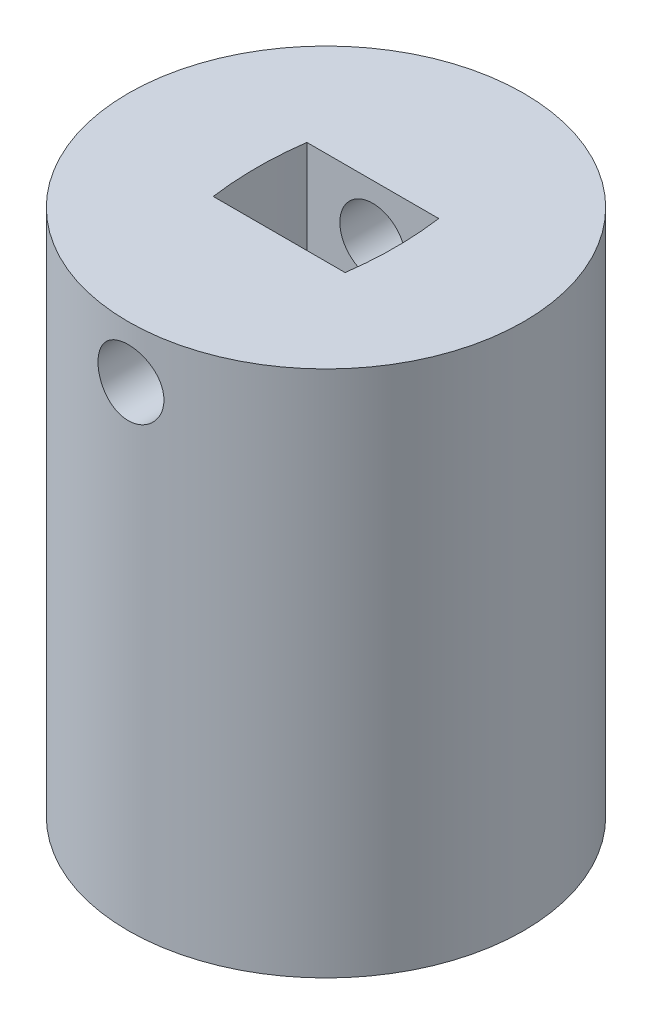
from build123d import *

# Parameters (mm, degrees)
SKETCH1_R               = 15
BOSS_EXTRUDE1_DEPTH     = 40
CUT_EXTRUDE1_DEPTH      = 15
SKETCH3_R               = 2
CUT_EXTRUDE2_DEPTH      = 15
CUT_EXTRUDE3_DEPTH      = 9
SKETCH5_R               = 2.5
CUT_EXTRUDE4_DEPTH      = 19.550000101
CUT_EXTRUDE4_DEPTH_BACK = 12.4500001


with BuildPart() as part:
    # Sketch1 → Boss-Extrude1 (new body)
    with BuildSketch(Plane(origin=(0, 0, 0), x_dir=(1, 0, 0), z_dir=(0, 1, 0))):
        Circle(SKETCH1_R)
    extrude(amount=BOSS_EXTRUDE1_DEPTH)

    # Sketch2 → Cut-Extrude1 (cut)
    with BuildSketch(Plane.XZ):
        with BuildLine():
            Line((-4.000002932, 5), (3.999997068, 5))
            add(Edge.make_bspline(
                [(3.999997068, 5), (8.199974497, 0.009249301), (3.999997068, -5)],
                knots=[0, 0, 0, 1, 1, 1], degree=2))
            Line((3.999997068, -5), (-4.000002932, -5))
            add(Edge.make_bspline(
                [(-4.000002932, 5), (-8.199982148, -0.00561634), (-4.000002932, -5)],
                knots=[0, 0, 0, 1, 1, 1], degree=2))
        make_face()
    extrude(amount=-CUT_EXTRUDE1_DEPTH, mode=Mode.SUBTRACT)

    # Sketch3 → Cut-Extrude2 (cut)
    with BuildSketch(Plane.XY.offset(-5)):
        with Locations((0, 12.004234523)):
            Circle(SKETCH3_R)
    extrude(amount=-CUT_EXTRUDE2_DEPTH, mode=Mode.SUBTRACT)

    # Sketch4 → Cut-Extrude3 (cut)
    with BuildSketch(Plane(origin=(0, 40, 0), x_dir=(1, 0, 0), z_dir=(0, 1, 0))):
        with BuildLine():
            Line((-5, 3.55), (5, 3.55))
            add(Edge.make_bspline(
                [(5, 3.55), (5.491620402, 0), (5, -3.55)],
                knots=[0, 0, 0, 1, 1, 1], degree=2))
            Line((5, -3.55), (-5, -3.55))
            add(Edge.make_bspline(
                [(-5, 3.55), (-5.491620402, 0), (-5, -3.55)],
                knots=[0, 0, 0, 1, 1, 1], degree=2))
        make_face()
    extrude(amount=-CUT_EXTRUDE3_DEPTH, mode=Mode.SUBTRACT)

    # Sketch5 → Cut-Extrude4 (cut, two sides)
    with BuildSketch(Plane(origin=(0, 0, 3.55), x_dir=(-1, 0, 0), z_dir=(0, 0, -1))) as cut_extrude4_sk:
        with Locations((0, 36)):
            Circle(SKETCH5_R)
    extrude(amount=CUT_EXTRUDE4_DEPTH, mode=Mode.SUBTRACT)
    extrude(cut_extrude4_sk.sketch, amount=-CUT_EXTRUDE4_DEPTH_BACK, mode=Mode.SUBTRACT)


solid = part.part
